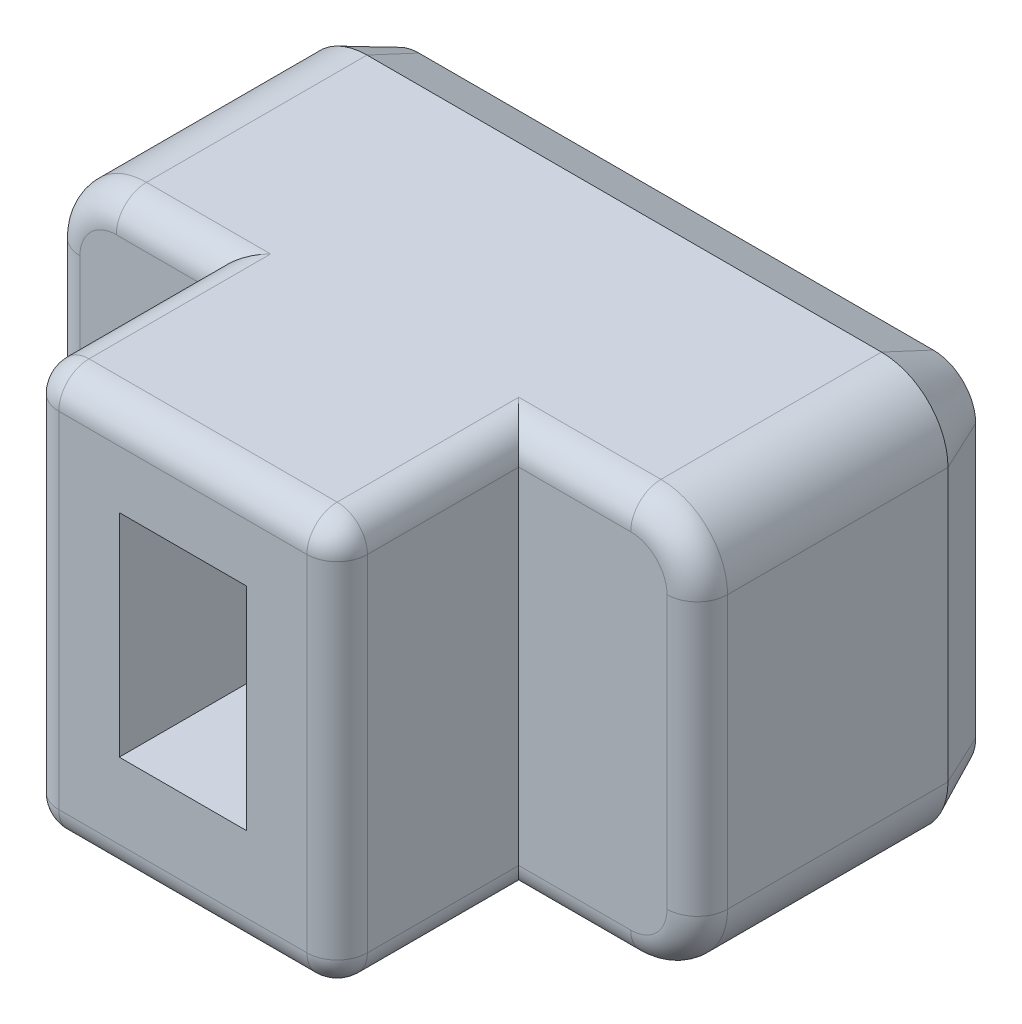
from build123d import *

# Parameters (mm, degrees)
BOSS_EXTRU_1_DEPTH      = 8
ESQUISSE3_W             = 2.1
ESQUISSE3_H             = 3.5
ENL_V_MAT_EXTRU_1_DEPTH = 3
ESQUISSE4_OUTSIDE_W     = 15.69
ESQUISSE4_OUTSIDE_H     = 11.69
ESQUISSE4_OUTSIDE_W_2   = 5.1
ESQUISSE4_OUTSIDE_H_2   = 6.7
ENL_V_MAT_EXTRU_2_DEPTH = 3
CONG_1_R                = 0.5
CHANFREIN1_SIZE         = 0.4
CHANFREIN1_SIZE2        = 0.857802768
ENL_V_MAT_EXTRU_3_DEPTH = 0.2
BOSS_EXTRU_2_DEPTH      = 0.2
BOSS_EXTRU_2_2_DEPTH    = 0.2
BOSS_EXTRU_2_3_DEPTH    = 0.2


with BuildPart() as part:
    # Esquisse2 → Boss.-Extru.1 (new body)
    with BuildSketch(Plane.XY):
        with BuildLine():
            Line((1.1, 0), (9.6, 0))
            ThreePointArc((9.6, 0), (10.377817459, 0.322182541), (10.7, 1.1))
            Line((10.7, 1.1), (10.7, 5.6))
            ThreePointArc((10.7, 5.6), (10.377817459, 6.377817459), (9.6, 6.7))
            Line((9.6, 6.7), (1.1, 6.7))
            ThreePointArc((1.1, 6.7), (0.322182541, 6.377817459), (0, 5.6))
            Line((0, 5.6), (0, 1.1))
            ThreePointArc((0, 1.1), (0.322182541, 0.322182541), (1.1, 0))
        make_face()
    extrude(amount=BOSS_EXTRU_1_DEPTH)

    # Esquisse3 → Enlèv. mat.-Extru.1 (cut)
    with BuildSketch(Plane.XY.offset(8)):
        with Locations((5.2, 3.5)):
            Rectangle(ESQUISSE3_W, ESQUISSE3_H)
    extrude(amount=-ENL_V_MAT_EXTRU_1_DEPTH, mode=Mode.SUBTRACT)

    # Esquisse4 outside → Enlèv. mat.-Extru.2 (cut)
    with BuildSketch(Plane.XY.offset(8)):
        with Locations((5.35, 3.35)):
            Rectangle(ESQUISSE4_OUTSIDE_W, ESQUISSE4_OUTSIDE_H)
        with Locations((5.2, 3.35)):
            Rectangle(ESQUISSE4_OUTSIDE_W_2, ESQUISSE4_OUTSIDE_H_2, mode=Mode.SUBTRACT)
    extrude(amount=-ENL_V_MAT_EXTRU_2_DEPTH, mode=Mode.SUBTRACT)

    # Congé1
    cong_1_edges = [part.edges().sort_by_distance(p)[0] for p in [
        (8.675, 0, 5),
        (10.377817459, 0.322182541, 5),
        (10.7, 3.35, 5),
        (10.377817459, 6.377817459, 5),
        (1.875, 6.7, 5),
        (0.322182541, 6.377817459, 5),
        (1.875, 0, 5),
        (0.322182541, 0.322182541, 5),
        (7.75, 6.7, 6.5),
        (2.65, 6.7, 6.5),
        (7.75, 0, 6.5),
        (2.65, 0, 6.5),
        (2.65, 3.35, 8),
        (5.2, 6.7, 8),
        (7.75, 3.35, 8),
        (5.2, 0, 8),
        (8.675, 6.7, 5),
        (0, 3.35, 5),
    ]]
    fillet(cong_1_edges, radius=CONG_1_R)

    # Chanfrein1
    chanfrein1_edges = [part.edges().sort_by_distance(p)[0] for p in [
        (5.35, 0, 0),
        (10.377817459, 0.322182541, 0),
        (0.322182541, 0.322182541, 0),
        (10.7, 3.35, 0),
        (0, 3.35, 0),
        (10.377817459, 6.377817459, 0),
        (0.322182541, 6.377817459, 0),
        (5.35, 6.7, 0),
    ]]
    chanfrein1_side = [part.faces().sort_by_distance(p)[0] for p in [
        (5.35, 3.35, 0),
    ]]
    chamfer(chanfrein1_edges, length=CHANFREIN1_SIZE, length2=CHANFREIN1_SIZE2, reference=chanfrein1_side[0])

    # Esquisse5 → Enlèv. mat.-Extru.3 (cut)
    # profile 1 of 3: a face of its own
    with BuildSketch(Plane.XY):
        Polygon((3.382593084, 1.356639893), (4.715926417, 5.356639893), (4.38099052, 5.356639893), (3.953907187, 4.074588611), (2.75999693, 4.074588611), (2.332913597, 5.356639893), (1.997977699, 5.356639893), (3.331311033, 1.356639893), align=None)
        Polygon((3.356952058, 2.284524508), (2.897016161, 3.6643322), (3.816887956, 3.6643322), align=None, mode=Mode.SUBTRACT)
    # profile 2 of 3: a face of its own
    with BuildSketch(Plane.XY):
        Polygon((5.382593084, 1.356639893), (5.690285392, 1.356639893), (5.690285392, 4.946383482), (6.921054623, 4.946383482), (6.921054623, 5.356639893), (5.382593084, 5.356639893), align=None)
    # profile 3 of 3: a face of its own
    with BuildSketch(Plane.XY):
        Polygon((7.074900776, 1.766896303), (7.074900776, 1.356639893), (8.715926417, 1.356639893), (8.715926417, 1.766896303), (8.049259751, 1.766896303), (8.049259751, 5.356639893), (7.741567443, 5.356639893), (7.741567443, 1.766896303), align=None)
    extrude(amount=ENL_V_MAT_EXTRU_3_DEPTH, mode=Mode.SUBTRACT)


with BuildPart() as body_2:
    # Esquisse5_4 → Boss.-Extru.2 (new body)
    with BuildSketch(Plane.XY):
        Polygon((3.382593084, 1.356639893), (4.715926417, 5.356639893), (4.38099052, 5.356639893), (3.953907187, 4.074588611), (2.75999693, 4.074588611), (2.332913597, 5.356639893), (1.997977699, 5.356639893), (3.331311033, 1.356639893), align=None)
        Polygon((3.356952058, 2.284524508), (2.897016161, 3.6643322), (3.816887956, 3.6643322), align=None, mode=Mode.SUBTRACT)
    extrude(amount=-BOSS_EXTRU_2_DEPTH)


with BuildPart() as body_3:
    # Esquisse5_4 → Boss.-Extru.2 2 (new body)
    with BuildSketch(Plane.XY):
        Polygon((5.382593084, 1.356639893), (5.690285392, 1.356639893), (5.690285392, 4.946383482), (6.921054623, 4.946383482), (6.921054623, 5.356639893), (5.382593084, 5.356639893), align=None)
    extrude(amount=-BOSS_EXTRU_2_2_DEPTH)


with BuildPart() as body_4:
    # Esquisse5_4 → Boss.-Extru.2 3 (new body)
    with BuildSketch(Plane.XY):
        Polygon((7.074900776, 1.766896303), (7.074900776, 1.356639893), (8.715926417, 1.356639893), (8.715926417, 1.766896303), (8.049259751, 1.766896303), (8.049259751, 5.356639893), (7.741567443, 5.356639893), (7.741567443, 1.766896303), align=None)
    extrude(amount=-BOSS_EXTRU_2_3_DEPTH)


solid = Compound([part.part, body_2.part, body_3.part, body_4.part])
